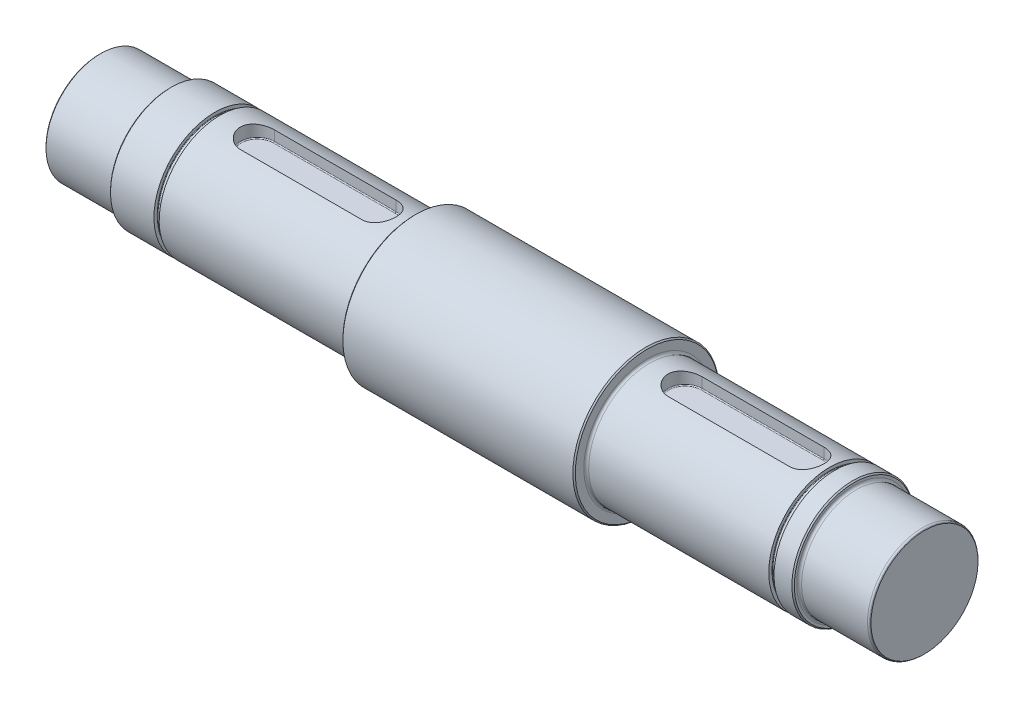
from build123d import *

# Parameters (mm, degrees)
FILLET1_R          = 0.2
CUT_EXTRUDE1_DEPTH = 5.5
CUT_EXTRUDE2_DEPTH = 5.5
CHAMFER1_SIZE      = 0.5
FILLET2_R          = 1
FILLET3_R          = 0.4


with BuildPart() as part:
    # Sketch1 → Revolve1 (revolve)
    with BuildSketch(Plane.XY):
        Polygon((-187.597560976, 22.5), (-187.597560976, 45), (-158.597560976, 45), (-158.597560976, 47.5), (-140.247560976, 47.5), (-140.247560976, 46), (-138.097560976, 46), (-138.097560976, 47.5), (-58.097560976, 47.5), (-58.097560976, 52.5), (37.402439024, 52.5), (37.402439024, 47.5), (112.402439024, 47.5), (112.402439024, 46), (114.552439024, 46), (114.552439024, 47.5), (122.402439024, 47.5), (122.402439024, 45), (151.402439024, 45), (151.402439024, 22.5), align=None)
    revolve(axis=Axis((151.402439024, 22.5, 0), (-1, 0, 0)))

    # Fillet1
    fillet1_edges = [part.edges().sort_by_distance(p)[0] for p in [
        (114.552439024, -1, 0),
        (112.402439024, -1, 0),
        (-138.097560976, -1, 0),
        (-140.247560976, -1, 0),
    ]]
    fillet(fillet1_edges, radius=FILLET1_R)

    # Sketch3 → Cut-Extrude1 (cut)
    with BuildSketch(Plane(origin=(0, 47.5, 0), x_dir=(1, 0, 0), z_dir=(0, 1, 0))):
        with BuildLine():
            Line((103.039419427, -7), (53.039419427, -7))
            ThreePointArc((53.039419427, -7), (46.039419427, 0), (53.039419427, 7))
            Line((53.039419427, 7), (103.039419427, 7))
            ThreePointArc((103.039419427, 7), (110.039419427, 0), (103.039419427, -7))
        make_face()
    extrude(amount=-CUT_EXTRUDE1_DEPTH, mode=Mode.SUBTRACT)

    # Sketch2 → Cut-Extrude2 (cut)
    with BuildSketch(Plane(origin=(0, 47.5, 0), x_dir=(1, 0, 0), z_dir=(0, 1, 0))):
        with BuildLine():
            Line((-72.751899335, -7), (-122.751899335, -7))
            ThreePointArc((-122.751899335, -7), (-129.751899335, 0), (-122.751899335, 7))
            Line((-122.751899335, 7), (-72.751899335, 7))
            ThreePointArc((-72.751899335, 7), (-65.751899335, 0), (-72.751899335, -7))
        make_face()
    extrude(amount=-CUT_EXTRUDE2_DEPTH, mode=Mode.SUBTRACT)

    # Chamfer1
    chamfer1_edges = [part.edges().sort_by_distance(p)[0] for p in [
        (151.402439024, 0, 0),
        (122.402439024, -2.5, 0),
        (37.402439024, -7.5, 0),
        (-58.097560976, -7.5, 0),
        (-158.597560976, -2.5, 0),
        (-187.597560976, 0, 0),
    ]]
    chamfer(chamfer1_edges, length=CHAMFER1_SIZE)

    # Fillet2
    fillet2_edges = [part.edges().sort_by_distance(p)[0] for p in [
        (122.402439024, 0, 0),
        (37.402439024, -2.5, 0),
        (-58.097560976, -2.5, 0),
        (-158.597560976, 0, 0),
        (150.902439024, 0, 0),
    ]]
    fillet(fillet2_edges, radius=FILLET2_R)

    # Fillet3
    fillet3_edges = [part.edges().sort_by_distance(p)[0] for p in [
        (110.039419427, 42, 0),
        (78.039419427, 42, 7),
        (46.039419427, 42, 0),
        (78.039419427, 42, -7),
        (-65.751899335, 42, 0),
        (-129.751899335, 42, 0),
        (-97.751899335, 42, -7),
        (-97.751899335, 42, 7),
    ]]
    fillet(fillet3_edges, radius=FILLET3_R)


solid = part.part
